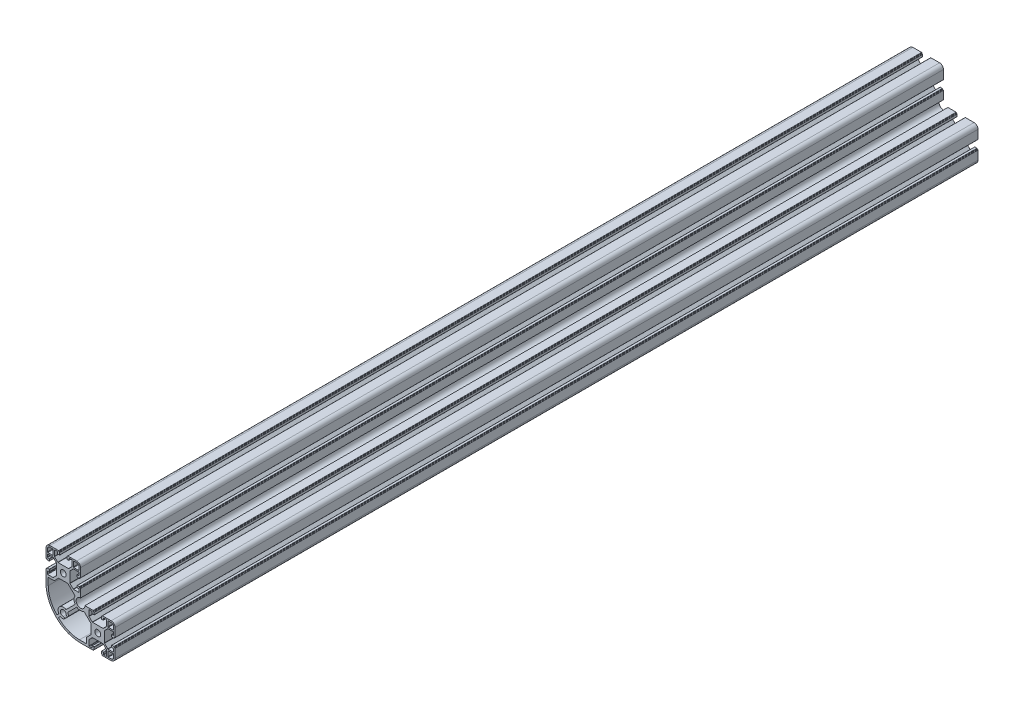
from build123d import *

# Parameters (mm, degrees)
SKETCH_1_R      = 3.4
EXTRUDE_1_DEPTH = 1000


with BuildPart() as part:
    # Эскиз1 → Бобышка-Вытянуть1 (new body)
    with BuildSketch(Plane.XY):
        with BuildLine():
            Line((-20, 10.25), (-20, 15.5))
            ThreePointArc((-20, 15.5), (-18.681980515, 18.681980515), (-15.5, 20))
            Line((-15.5, 20), (-10.25, 20))
            Line((-10.25, 20), (-5.4, 20))
            ThreePointArc((-5.4, 20), (-5.187867966, 19.912132034), (-5.1, 19.7))
            Line((-5.1, 19.7), (-5.1, 19.3))
            ThreePointArc((-5.1, 19.3), (-5.012132034, 19.087867966), (-4.8, 19))
            Line((-4.8, 19), (-4.4, 19))
            ThreePointArc((-4.4, 19), (-4.187867966, 18.912132034), (-4.1, 18.7))
            Line((-4.1, 18.7), (-4.1, 16.3))
            ThreePointArc((-4.1, 16.3), (-4.187867966, 16.087867966), (-4.4, 16))
            Line((-4.4, 16), (-6.3, 16))
            ThreePointArc((-6.3, 16), (-6.512132034, 16.087867966), (-6.6, 16.3))
            Line((-6.6, 16.3), (-6.6, 18))
            ThreePointArc((-6.6, 18), (-6.746446609, 18.353553391), (-7.1, 18.5))
            Line((-7.1, 18.5), (-9.75, 18.5))
            ThreePointArc((-9.75, 18.5), (-10.103553391, 18.353553391), (-10.25, 18))
            Line((-10.25, 18), (-10.25, 11.907106781))
            ThreePointArc((-10.25, 11.907106781), (-10.211939766, 11.715765065), (-10.103553391, 11.553553391))
            Line((-10.103553391, 11.553553391), (-6.396446609, 7.846446609))
            ThreePointArc((-6.396446609, 7.846446609), (-6.234234935, 7.738060234), (-6.042893219, 7.7))
            Line((-6.042893219, 7.7), (6.042893219, 7.7))
            ThreePointArc((6.042893219, 7.7), (6.234234935, 7.738060234), (6.396446609, 7.846446609))
            Line((6.396446609, 7.846446609), (10.103553391, 11.553553391))
            ThreePointArc((10.103553391, 11.553553391), (10.211939766, 11.715765065), (10.25, 11.907106781))
            Line((10.25, 11.907106781), (10.25, 18))
            ThreePointArc((10.25, 18), (10.103553391, 18.353553391), (9.75, 18.5))
            Line((9.75, 18.5), (7.1, 18.5))
            ThreePointArc((7.1, 18.5), (6.746446609, 18.353553391), (6.6, 18))
            Line((6.6, 18), (6.6, 16.3))
            ThreePointArc((6.6, 16.3), (6.512132034, 16.087867966), (6.3, 16))
            Line((6.3, 16), (4.4, 16))
            ThreePointArc((4.4, 16), (4.187867966, 16.087867966), (4.1, 16.3))
            Line((4.1, 16.3), (4.1, 18.7))
            ThreePointArc((4.1, 18.7), (4.187867966, 18.912132034), (4.4, 19))
            Line((4.4, 19), (4.8, 19))
            ThreePointArc((4.8, 19), (5.012132034, 19.087867966), (5.1, 19.3))
            Line((5.1, 19.3), (5.1, 19.7))
            ThreePointArc((5.1, 19.7), (5.187867966, 19.912132034), (5.4, 20))
            Line((5.4, 20), (10.25, 20))
            Line((10.25, 20), (15.5, 20))
            ThreePointArc((15.5, 20), (18.681980515, 18.681980515), (20, 15.5))
            Line((20, 15.5), (20, 10.25))
            Line((20, 10.25), (20, 5.4))
            ThreePointArc((20, 5.4), (19.912132034, 5.187867966), (19.7, 5.1))
            Line((19.7, 5.1), (19.3, 5.1))
            ThreePointArc((19.3, 5.1), (19.087867966, 5.012132034), (19, 4.8))
            Line((19, 4.8), (19, 4.4))
            ThreePointArc((19, 4.4), (18.912132034, 4.187867966), (18.7, 4.1))
            Line((18.7, 4.1), (16.3, 4.1))
            ThreePointArc((16.3, 4.1), (16.087867966, 4.187867966), (16, 4.4))
            Line((16, 4.4), (16, 6.3))
            ThreePointArc((16, 6.3), (16.087867966, 6.512132034), (16.3, 6.6))
            Line((16.3, 6.6), (18, 6.6))
            ThreePointArc((18, 6.6), (18.353553391, 6.746446609), (18.5, 7.1))
            Line((18.5, 7.1), (18.5, 9.75))
            ThreePointArc((18.5, 9.75), (18.353553391, 10.103553391), (18, 10.25))
            Line((18, 10.25), (11.907106781, 10.25))
            ThreePointArc((11.907106781, 10.25), (11.715765065, 10.211939766), (11.553553391, 10.103553391))
            Line((11.553553391, 10.103553391), (7.846446609, 6.396446609))
            ThreePointArc((7.846446609, 6.396446609), (7.738060234, 6.234234935), (7.7, 6.042893219))
            Line((7.7, 6.042893219), (7.7, -6.042893219))
            ThreePointArc((7.7, -6.042893219), (7.738060234, -6.234234935), (7.846446609, -6.396446609))
            Line((7.846446609, -6.396446609), (11.553553391, -10.103553391))
            ThreePointArc((11.553553391, -10.103553391), (11.715765065, -10.211939766), (11.907106781, -10.25))
            Line((11.907106781, -10.25), (18, -10.25))
            ThreePointArc((18, -10.25), (18.353553391, -10.103553391), (18.5, -9.75))
            Line((18.5, -9.75), (18.5, -7.1))
            ThreePointArc((18.5, -7.1), (18.353553391, -6.746446609), (18, -6.6))
            Line((18, -6.6), (16.3, -6.6))
            ThreePointArc((16.3, -6.6), (16.087867966, -6.512132034), (16, -6.3))
            Line((16, -6.3), (16, -4.4))
            ThreePointArc((16, -4.4), (16.087867966, -4.187867966), (16.3, -4.1))
            Line((16.3, -4.1), (18.7, -4.1))
            ThreePointArc((18.7, -4.1), (18.912132034, -4.187867966), (19, -4.4))
            Line((19, -4.4), (19, -4.8))
            ThreePointArc((19, -4.8), (19.087867966, -5.012132034), (19.3, -5.1))
            Line((19.3, -5.1), (19.7, -5.1))
            ThreePointArc((19.7, -5.1), (19.912132034, -5.187867966), (20, -5.4))
            Line((20, -5.4), (20, -10.25))
            Line((20, -10.25), (20, -14.9))
            ThreePointArc((20, -14.9), (16.393755416, -23.606244584), (25.1, -20))
            Line((25.1, -20), (29.75, -20))
            Line((29.75, -20), (34.6, -20))
            ThreePointArc((34.6, -20), (34.812132034, -20.087867966), (34.9, -20.3))
            Line((34.9, -20.3), (34.9, -20.7))
            ThreePointArc((34.9, -20.7), (34.987867966, -20.912132034), (35.2, -21))
            Line((35.2, -21), (35.6, -21))
            ThreePointArc((35.6, -21), (35.812132034, -21.087867966), (35.9, -21.3))
            Line((35.9, -21.3), (35.9, -23.7))
            ThreePointArc((35.9, -23.7), (35.812132034, -23.912132034), (35.6, -24))
            Line((35.6, -24), (33.7, -24))
            ThreePointArc((33.7, -24), (33.487867966, -23.912132034), (33.4, -23.7))
            Line((33.4, -23.7), (33.4, -22))
            ThreePointArc((33.4, -22), (33.253553391, -21.646446609), (32.9, -21.5))
            Line((32.9, -21.5), (30.25, -21.5))
            ThreePointArc((30.25, -21.5), (29.896446609, -21.646446609), (29.75, -22))
            Line((29.75, -22), (29.75, -28.092893219))
            ThreePointArc((29.75, -28.092893219), (29.788060234, -28.284234935), (29.896446609, -28.446446609))
            Line((29.896446609, -28.446446609), (33.603553391, -32.153553391))
            ThreePointArc((33.603553391, -32.153553391), (33.765765065, -32.261939766), (33.957106781, -32.3))
            Line((33.957106781, -32.3), (46.042893219, -32.3))
            ThreePointArc((46.042893219, -32.3), (46.234234935, -32.261939766), (46.396446609, -32.153553391))
            Line((46.396446609, -32.153553391), (50.103553391, -28.446446609))
            ThreePointArc((50.103553391, -28.446446609), (50.211939766, -28.284234935), (50.25, -28.092893219))
            Line((50.25, -28.092893219), (50.25, -22))
            ThreePointArc((50.25, -22), (50.103553391, -21.646446609), (49.75, -21.5))
            Line((49.75, -21.5), (47.1, -21.5))
            ThreePointArc((47.1, -21.5), (46.746446609, -21.646446609), (46.6, -22))
            Line((46.6, -22), (46.6, -23.7))
            ThreePointArc((46.6, -23.7), (46.512132034, -23.912132034), (46.3, -24))
            Line((46.3, -24), (44.4, -24))
            ThreePointArc((44.4, -24), (44.187867966, -23.912132034), (44.1, -23.7))
            Line((44.1, -23.7), (44.1, -21.3))
            ThreePointArc((44.1, -21.3), (44.187867966, -21.087867966), (44.4, -21))
            Line((44.4, -21), (44.8, -21))
            ThreePointArc((44.8, -21), (45.012132034, -20.912132034), (45.1, -20.7))
            Line((45.1, -20.7), (45.1, -20.3))
            ThreePointArc((45.1, -20.3), (45.187867966, -20.087867966), (45.4, -20))
            Line((45.4, -20), (50.25, -20))
            Line((50.25, -20), (55.5, -20))
            ThreePointArc((55.5, -20), (58.681980515, -21.318019485), (60, -24.5))
            Line((60, -24.5), (60, -29.75))
            Line((60, -29.75), (60, -34.6))
            ThreePointArc((60, -34.6), (59.912132034, -34.812132034), (59.7, -34.9))
            Line((59.7, -34.9), (59.3, -34.9))
            ThreePointArc((59.3, -34.9), (59.087867966, -34.987867966), (59, -35.2))
            Line((59, -35.2), (59, -35.6))
            ThreePointArc((59, -35.6), (58.912132034, -35.812132034), (58.7, -35.9))
            Line((58.7, -35.9), (56.3, -35.9))
            ThreePointArc((56.3, -35.9), (56.087867966, -35.812132034), (56, -35.6))
            Line((56, -35.6), (56, -33.7))
            ThreePointArc((56, -33.7), (56.087867966, -33.487867966), (56.3, -33.4))
            Line((56.3, -33.4), (58, -33.4))
            ThreePointArc((58, -33.4), (58.353553391, -33.253553391), (58.5, -32.9))
            Line((58.5, -32.9), (58.5, -30.25))
            ThreePointArc((58.5, -30.25), (58.353553391, -29.896446609), (58, -29.75))
            Line((58, -29.75), (51.907106781, -29.75))
            ThreePointArc((51.907106781, -29.75), (51.715765065, -29.788060234), (51.553553391, -29.896446609))
            Line((51.553553391, -29.896446609), (47.846446609, -33.603553391))
            ThreePointArc((47.846446609, -33.603553391), (47.738060234, -33.765765065), (47.7, -33.957106781))
            Line((47.7, -33.957106781), (47.7, -46.042893219))
            ThreePointArc((47.7, -46.042893219), (47.738060234, -46.234234935), (47.846446609, -46.396446609))
            Line((47.846446609, -46.396446609), (51.553553391, -50.103553391))
            ThreePointArc((51.553553391, -50.103553391), (51.715765065, -50.211939766), (51.907106781, -50.25))
            Line((51.907106781, -50.25), (58, -50.25))
            ThreePointArc((58, -50.25), (58.353553391, -50.103553391), (58.5, -49.75))
            Line((58.5, -49.75), (58.5, -47.1))
            ThreePointArc((58.5, -47.1), (58.353553391, -46.746446609), (58, -46.6))
            Line((58, -46.6), (56.3, -46.6))
            ThreePointArc((56.3, -46.6), (56.087867966, -46.512132034), (56, -46.3))
            Line((56, -46.3), (56, -44.4))
            ThreePointArc((56, -44.4), (56.087867966, -44.187867966), (56.3, -44.1))
            Line((56.3, -44.1), (58.7, -44.1))
            ThreePointArc((58.7, -44.1), (58.912132034, -44.187867966), (59, -44.4))
            Line((59, -44.4), (59, -44.8))
            ThreePointArc((59, -44.8), (59.087867966, -45.012132034), (59.3, -45.1))
            Line((59.3, -45.1), (59.7, -45.1))
            ThreePointArc((59.7, -45.1), (59.912132034, -45.187867966), (60, -45.4))
            Line((60, -45.4), (60, -50.25))
            Line((60, -50.25), (60, -55.5))
            ThreePointArc((60, -55.5), (58.681980515, -58.681980515), (55.5, -60))
            Line((55.5, -60), (50.25, -60))
            Line((50.25, -60), (45.4, -60))
            ThreePointArc((45.4, -60), (45.187867966, -59.912132034), (45.1, -59.7))
            Line((45.1, -59.7), (45.1, -59.3))
            ThreePointArc((45.1, -59.3), (45.012132034, -59.087867966), (44.8, -59))
            Line((44.8, -59), (44.4, -59))
            ThreePointArc((44.4, -59), (44.187867966, -58.912132034), (44.1, -58.7))
            Line((44.1, -58.7), (44.1, -56.3))
            ThreePointArc((44.1, -56.3), (44.187867966, -56.087867966), (44.4, -56))
            Line((44.4, -56), (46.3, -56))
            ThreePointArc((46.3, -56), (46.512132034, -56.087867966), (46.6, -56.3))
            Line((46.6, -56.3), (46.6, -58))
            ThreePointArc((46.6, -58), (46.746446609, -58.353553391), (47.1, -58.5))
            Line((47.1, -58.5), (49.75, -58.5))
            ThreePointArc((49.75, -58.5), (50.103553391, -58.353553391), (50.25, -58))
            Line((50.25, -58), (50.25, -51.907106781))
            ThreePointArc((50.25, -51.907106781), (50.211939766, -51.715765065), (50.103553391, -51.553553391))
            Line((50.103553391, -51.553553391), (46.396446609, -47.846446609))
            ThreePointArc((46.396446609, -47.846446609), (46.234234935, -47.738060234), (46.042893219, -47.7))
            Line((46.042893219, -47.7), (33.957106781, -47.7))
            ThreePointArc((33.957106781, -47.7), (33.765765065, -47.738060234), (33.603553391, -47.846446609))
            Line((33.603553391, -47.846446609), (29.896446609, -51.553553391))
            ThreePointArc((29.896446609, -51.553553391), (29.788060234, -51.715765065), (29.75, -51.907106781))
            Line((29.75, -51.907106781), (29.75, -58))
            ThreePointArc((29.75, -58), (29.896446609, -58.353553391), (30.25, -58.5))
            Line((30.25, -58.5), (32.9, -58.5))
            ThreePointArc((32.9, -58.5), (33.253553391, -58.353553391), (33.4, -58))
            Line((33.4, -58), (33.4, -56.3))
            ThreePointArc((33.4, -56.3), (33.487867966, -56.087867966), (33.7, -56))
            Line((33.7, -56), (35.6, -56))
            ThreePointArc((35.6, -56), (35.812132034, -56.087867966), (35.9, -56.3))
            Line((35.9, -56.3), (35.9, -58.7))
            ThreePointArc((35.9, -58.7), (35.812132034, -58.912132034), (35.6, -59))
            Line((35.6, -59), (35.2, -59))
            ThreePointArc((35.2, -59), (34.987867966, -59.087867966), (34.9, -59.3))
            Line((34.9, -59.3), (34.9, -59.7))
            ThreePointArc((34.9, -59.7), (34.812132034, -59.912132034), (34.6, -60))
            Line((34.6, -60), (29.75, -60))
            Line((29.75, -60), (20, -60))
            ThreePointArc((20, -60), (-8.284271247, -48.284271247), (-20, -20))
            Line((-20, -20), (-20, -10.25))
            Line((-20, -10.25), (-20, -5.4))
            ThreePointArc((-20, -5.4), (-19.912132034, -5.187867966), (-19.7, -5.1))
            Line((-19.7, -5.1), (-19.3, -5.1))
            ThreePointArc((-19.3, -5.1), (-19.087867966, -5.012132034), (-19, -4.8))
            Line((-19, -4.8), (-19, -4.4))
            ThreePointArc((-19, -4.4), (-18.912132034, -4.187867966), (-18.7, -4.1))
            Line((-18.7, -4.1), (-16.3, -4.1))
            ThreePointArc((-16.3, -4.1), (-16.087867966, -4.187867966), (-16, -4.4))
            Line((-16, -4.4), (-16, -6.3))
            ThreePointArc((-16, -6.3), (-16.087867966, -6.512132034), (-16.3, -6.6))
            Line((-16.3, -6.6), (-18, -6.6))
            ThreePointArc((-18, -6.6), (-18.353553391, -6.746446609), (-18.5, -7.1))
            Line((-18.5, -7.1), (-18.5, -9.75))
            ThreePointArc((-18.5, -9.75), (-18.353553391, -10.103553391), (-18, -10.25))
            Line((-18, -10.25), (-11.907106781, -10.25))
            ThreePointArc((-11.907106781, -10.25), (-11.715765065, -10.211939766), (-11.553553391, -10.103553391))
            Line((-11.553553391, -10.103553391), (-7.846446609, -6.396446609))
            ThreePointArc((-7.846446609, -6.396446609), (-7.738060234, -6.234234935), (-7.7, -6.042893219))
            Line((-7.7, -6.042893219), (-7.7, 6.042893219))
            ThreePointArc((-7.7, 6.042893219), (-7.738060234, 6.234234935), (-7.846446609, 6.396446609))
            Line((-7.846446609, 6.396446609), (-11.553553391, 10.103553391))
            ThreePointArc((-11.553553391, 10.103553391), (-11.715765065, 10.211939766), (-11.907106781, 10.25))
            Line((-11.907106781, 10.25), (-18, 10.25))
            ThreePointArc((-18, 10.25), (-18.353553391, 10.103553391), (-18.5, 9.75))
            Line((-18.5, 9.75), (-18.5, 7.1))
            ThreePointArc((-18.5, 7.1), (-18.353553391, 6.746446609), (-18, 6.6))
            Line((-18, 6.6), (-16.3, 6.6))
            ThreePointArc((-16.3, 6.6), (-16.087867966, 6.512132034), (-16, 6.3))
            Line((-16, 6.3), (-16, 4.4))
            ThreePointArc((-16, 4.4), (-16.087867966, 4.187867966), (-16.3, 4.1))
            Line((-16.3, 4.1), (-18.7, 4.1))
            ThreePointArc((-18.7, 4.1), (-18.912132034, 4.187867966), (-19, 4.4))
            Line((-19, 4.4), (-19, 4.8))
            ThreePointArc((-19, 4.8), (-19.087867966, 5.012132034), (-19.3, 5.1))
            Line((-19.3, 5.1), (-19.7, 5.1))
            ThreePointArc((-19.7, 5.1), (-19.912132034, 5.187867966), (-20, 5.4))
            Line((-20, 5.4), (-20, 10.25))
        make_face()
        Circle(SKETCH_1_R, mode=Mode.SUBTRACT)
        with Locations((40, -40)):
            Circle(SKETCH_1_R, mode=Mode.SUBTRACT)
        with BuildLine():
            Line((-12.3, 11.8), (-17.8, 11.8))
            ThreePointArc((-17.8, 11.8), (-18.153553391, 11.946446609), (-18.3, 12.3))
            Line((-18.3, 12.3), (-18.3, 15.5))
            ThreePointArc((-18.3, 15.5), (-17.479898987, 17.479898987), (-15.5, 18.3))
            Line((-15.5, 18.3), (-12.3, 18.3))
            ThreePointArc((-12.3, 18.3), (-11.946446609, 18.153553391), (-11.8, 17.8))
            Line((-11.8, 17.8), (-11.8, 12.3))
            ThreePointArc((-11.8, 12.3), (-11.946446609, 11.946446609), (-12.3, 11.8))
        make_face(mode=Mode.SUBTRACT)
        with BuildLine():
            Line((11.8, 12.3), (11.8, 17.8))
            ThreePointArc((11.8, 17.8), (11.946446609, 18.153553391), (12.3, 18.3))
            Line((12.3, 18.3), (15.5, 18.3))
            ThreePointArc((15.5, 18.3), (17.479898987, 17.479898987), (18.3, 15.5))
            Line((18.3, 15.5), (18.3, 12.3))
            ThreePointArc((18.3, 12.3), (18.153553391, 11.946446609), (17.8, 11.8))
            Line((17.8, 11.8), (12.3, 11.8))
            ThreePointArc((12.3, 11.8), (11.946446609, 11.946446609), (11.8, 12.3))
        make_face(mode=Mode.SUBTRACT)
        with BuildLine():
            Line((58.3, -52.3), (58.3, -55.5))
            ThreePointArc((58.3, -55.5), (57.479898987, -57.479898987), (55.5, -58.3))
            Line((55.5, -58.3), (52.3, -58.3))
            ThreePointArc((52.3, -58.3), (51.946446609, -58.153553391), (51.8, -57.8))
            Line((51.8, -57.8), (51.8, -52.3))
            ThreePointArc((51.8, -52.3), (51.946446609, -51.946446609), (52.3, -51.8))
            Line((52.3, -51.8), (57.8, -51.8))
            ThreePointArc((57.8, -51.8), (58.153553391, -51.946446609), (58.3, -52.3))
        make_face(mode=Mode.SUBTRACT)
        with BuildLine():
            Line((51.8, -27.7), (51.8, -22.2))
            ThreePointArc((51.8, -22.2), (51.946446609, -21.846446609), (52.3, -21.7))
            Line((52.3, -21.7), (55.5, -21.7))
            ThreePointArc((55.5, -21.7), (57.479898987, -22.520101013), (58.3, -24.5))
            Line((58.3, -24.5), (58.3, -27.7))
            ThreePointArc((58.3, -27.7), (58.153553391, -28.053553391), (57.8, -28.2))
            Line((57.8, -28.2), (52.3, -28.2))
            ThreePointArc((52.3, -28.2), (51.946446609, -28.053553391), (51.8, -27.7))
        make_face(mode=Mode.SUBTRACT)
        with BuildLine():
            Line((-17.4, -12.85), (-17.4, -21.15))
            ThreePointArc((-17.4, -21.15), (-14.78057883, -34.318719493), (-7.321098449, -45.482620818))
            Line((-7.321098449, -45.482620818), (-5.061098301, -43.22262067))
            ThreePointArc((-5.061098301, -43.22262067), (-4.242640687, -35.757359313), (3.22262067, -34.938901699))
            Line((3.22262067, -34.938901699), (13.857735242, -24.303787127))
            ThreePointArc((13.857735242, -24.303787127), (12.501305707, -20.139942462), (13.701431476, -15.928386738))
            Line((13.701431476, -15.928386738), (5.373044738, -7.6))
            Line((5.373044738, -7.6), (-5.373044738, -7.6))
            Line((-5.373044738, -7.6), (-10.623044738, -12.85))
            Line((-10.623044738, -12.85), (-17.4, -12.85))
        make_face(mode=Mode.SUBTRACT)
        with BuildLine():
            Line((-5.482620818, -47.321098449), (-3.22262067, -45.061098301))
            ThreePointArc((-3.22262067, -45.061098301), (-1.678304232, -45.760494328), (0, -46))
            ThreePointArc((0, -46), (1.3, -44.7), (0, -43.4))
            ThreePointArc((0, -43.4), (-2.404163056, -37.595836944), (3.4, -40))
            ThreePointArc((3.4, -40), (4.7, -41.3), (6, -40))
            ThreePointArc((6, -40), (5.760494328, -38.321695768), (5.061098301, -36.77737933))
            Line((5.061098301, -36.77737933), (15.696212873, -26.142264758))
            ThreePointArc((15.696212873, -26.142264758), (19.860057538, -27.498694293), (24.071613262, -26.298568524))
            Line((24.071613262, -26.298568524), (32.4, -34.626955262))
            Line((32.4, -34.626955262), (32.4, -45.373044738))
            Line((32.4, -45.373044738), (27.15, -50.623044738))
            Line((27.15, -50.623044738), (27.15, -57.4))
            Line((27.15, -57.4), (18.85, -57.4))
            ThreePointArc((18.85, -57.4), (5.681280507, -54.78057883), (-5.482620818, -47.321098449))
        make_face(mode=Mode.SUBTRACT)
    extrude(amount=EXTRUDE_1_DEPTH)


solid = part.part
